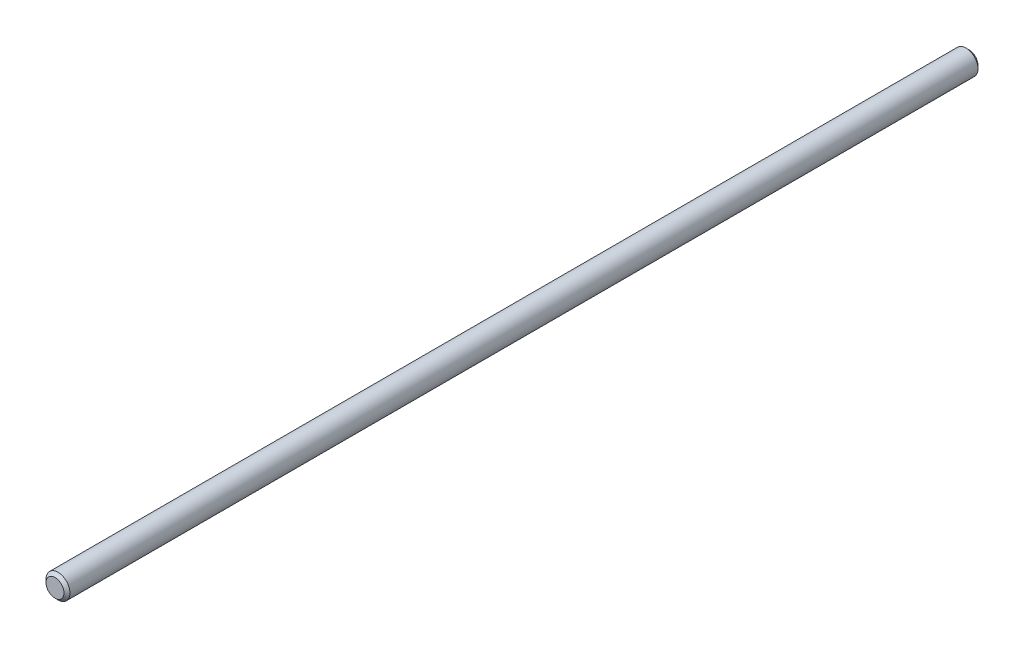
from build123d import *

# Parameters (mm, degrees)
SKETCH1_R           = 4
BOSS_EXTRUDE1_DEPTH = 305
CHAMFER2_SIZE       = 1
CHAMFER3_SIZE       = 1


with BuildPart() as part:
    # Sketch1 → Boss-Extrude1 (new body)
    with BuildSketch(Plane.XY):
        Circle(SKETCH1_R)
    extrude(amount=BOSS_EXTRUDE1_DEPTH)

    # Chamfer2
    chamfer2_edges = [part.edges().sort_by_distance(p)[0] for p in [
        (-4, 0, 0),
    ]]
    chamfer(chamfer2_edges, length=CHAMFER2_SIZE)

    # Chamfer3
    chamfer3_edges = [part.edges().sort_by_distance(p)[0] for p in [
        (-4, 0, 305),
    ]]
    chamfer(chamfer3_edges, length=CHAMFER3_SIZE)


solid = part.part
